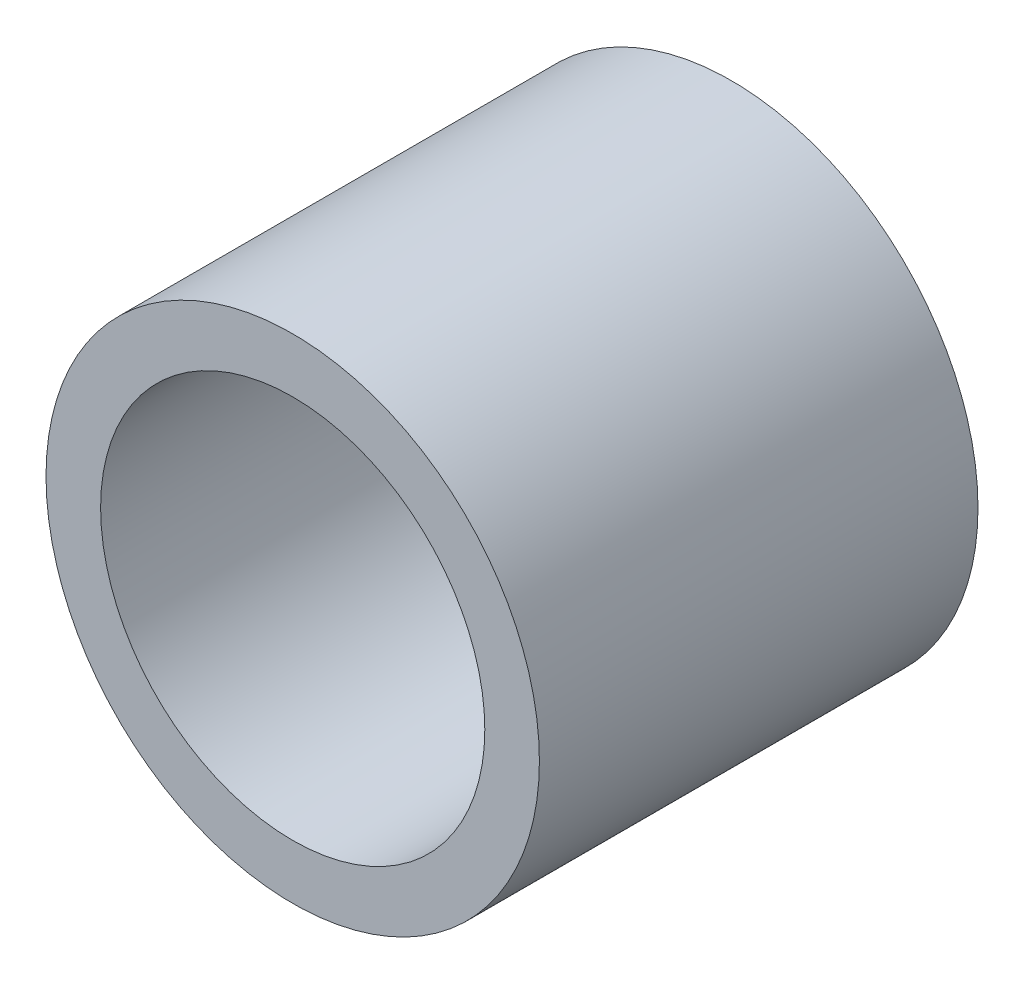
from build123d import *

# Parameters (mm, degrees)
SKETCH1_R      = 14.2875
SKETCH1_R_2    = 11.1252
EXTRUDE1_DEPTH = 12.7


with BuildPart() as part:
    # Sketch1 → Extrude1 (new body, symmetric)
    with BuildSketch(Plane.XY):
        Circle(SKETCH1_R)
        Circle(SKETCH1_R_2, mode=Mode.SUBTRACT)
    extrude(amount=EXTRUDE1_DEPTH, both=True)


solid = part.part
